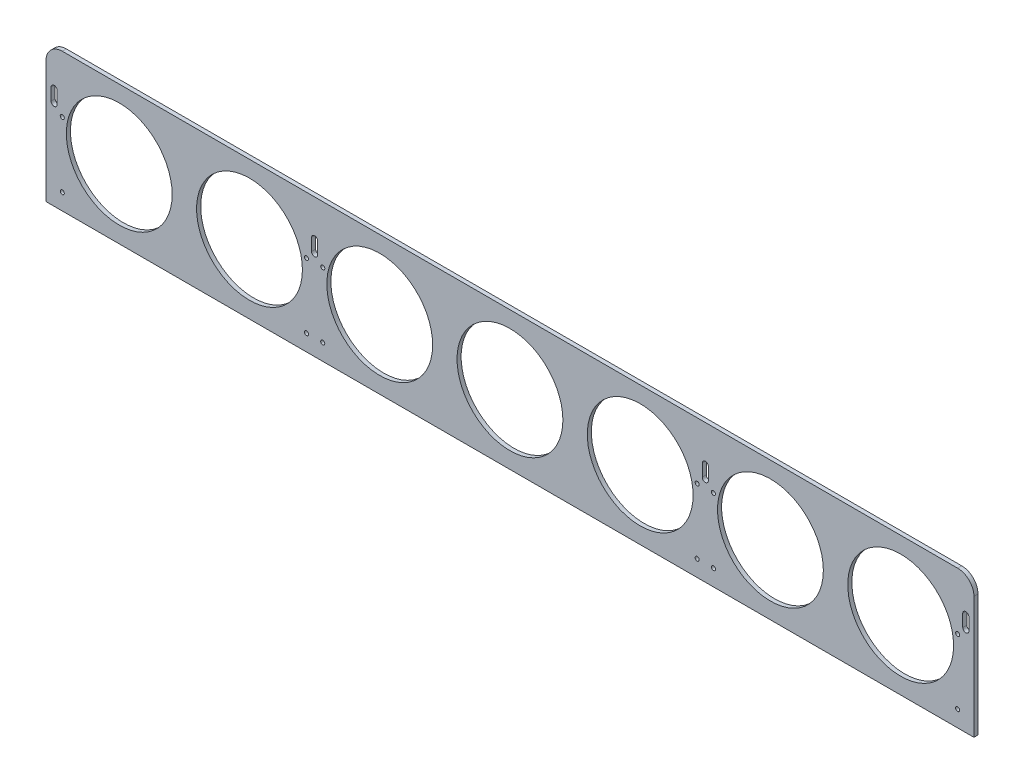
from build123d import *

# Parameters (mm, degrees)
SKETCH1_W            = 1447.8
SKETCH1_H            = 215.9
BOSS_EXTRUDE1_DEPTH  = 6.35
SKETCH2_R            = 82.55
CUT_EXTRUDE1_DEPTH   = 7.35
LPATTERN1_COUNT      = 7
LPATTERN1_PITCH      = 203.2
FILLET1_R            = 25.4
CUT_EXTRUDE2_DEPTH   = 7.35
LPATTERN2_COUNT      = 2
LPATTERN2_PITCH      = 406.4
MIRROR1_COPY_1_DEPTH = 7.35
SKETCH4_R            = 3.175
CUT_EXTRUDE3_DEPTH   = 7.35


with BuildPart() as part:
    # Sketch1 → Boss-Extrude1 (new body)
    with BuildSketch(Plane.XY):
        Rectangle(SKETCH1_W, SKETCH1_H)
    extrude(amount=BOSS_EXTRUDE1_DEPTH)

    # Sketch2 → Cut-Extrude1 (cut, through all)
    with BuildSketch(Plane.XY.offset(6.35)):
        with Locations((-609.6, 0)):
            Circle(SKETCH2_R)
    cut_extrude1 = extrude(amount=-CUT_EXTRUDE1_DEPTH, mode=Mode.SUBTRACT)

    # LPattern1: Cut-Extrude1 ×7
    with Locations(*[(i * LPATTERN1_PITCH, 0, 0) for i in range(1, LPATTERN1_COUNT)]):
        add(cut_extrude1, mode=Mode.SUBTRACT)

    # Fillet1
    fillet1_edges = [part.edges().sort_by_distance(p)[0] for p in [
        (-723.9, 107.95, 3.175),
        (723.9, 107.95, 3.175),
    ]]
    fillet(fillet1_edges, radius=FILLET1_R)

    # Sketch3 → Cut-Extrude2 (cut, through all)
    with BuildSketch(Plane.XY.offset(6.35)):
        with BuildLine():
            Line((-706.4375, 50.8), (-706.4375, 31.75))
            ThreePointArc((-706.4375, 31.75), (-711.2, 26.9875), (-715.9625, 31.75))
            Line((-715.9625, 31.75), (-715.9625, 50.8))
            ThreePointArc((-715.9625, 50.8), (-711.2, 55.5625), (-706.4375, 50.8))
        make_face()
    cut_extrude2 = extrude(amount=-CUT_EXTRUDE2_DEPTH, mode=Mode.SUBTRACT)

    # LPattern2: Cut-Extrude2 ×2
    with Locations(*[(i * LPATTERN2_PITCH, 0, 0) for i in range(1, LPATTERN2_COUNT)]):
        add(cut_extrude2, mode=Mode.SUBTRACT)

    # Mirror1: Cut-Extrude2 across plane
    add(cut_extrude2.mirror(Plane(origin=(0, 0, 0), x_dir=(0, 0, 1), z_dir=(1, 0, 0))), mode=Mode.SUBTRACT)

    # Mirror1 copy 1 sketch → Mirror1 copy 1 (cut, through all)
    with BuildSketch(Plane(origin=(-406.4, 0, 6.35), x_dir=(-1, 0, 0), z_dir=(0, 0, 1))):
        with BuildLine():
            Line((-706.4375, -50.8), (-706.4375, -31.75))
            ThreePointArc((-706.4375, -31.75), (-711.2, -26.9875), (-715.9625, -31.75))
            Line((-715.9625, -31.75), (-715.9625, -50.8))
            ThreePointArc((-715.9625, -50.8), (-711.2, -55.5625), (-706.4375, -50.8))
        make_face()
    extrude(amount=-MIRROR1_COPY_1_DEPTH, mode=Mode.SUBTRACT)

    # Sketch4 → Cut-Extrude3 (cut, through all)
    with BuildSketch(Plane.XY.offset(6.35)):
        with Locations((-698.5, 19.05)):
            Circle(SKETCH4_R)
        with Locations((-317.5, 19.05)):
            Circle(SKETCH4_R)
        with Locations((-292.1, 19.05)):
            Circle(SKETCH4_R)
        with Locations((-698.5, -82.55)):
            Circle(SKETCH4_R)
        with Locations((-317.5, -82.55)):
            Circle(SKETCH4_R)
        with Locations((-292.1, -82.55)):
            Circle(SKETCH4_R)
    cut_extrude3 = extrude(amount=-CUT_EXTRUDE3_DEPTH, mode=Mode.SUBTRACT)

    # Mirror2: Cut-Extrude3 across plane
    add(cut_extrude3.mirror(Plane(origin=(0, 0, 0), x_dir=(0, 0, 1), z_dir=(1, 0, 0))), mode=Mode.SUBTRACT)


solid = part.part
